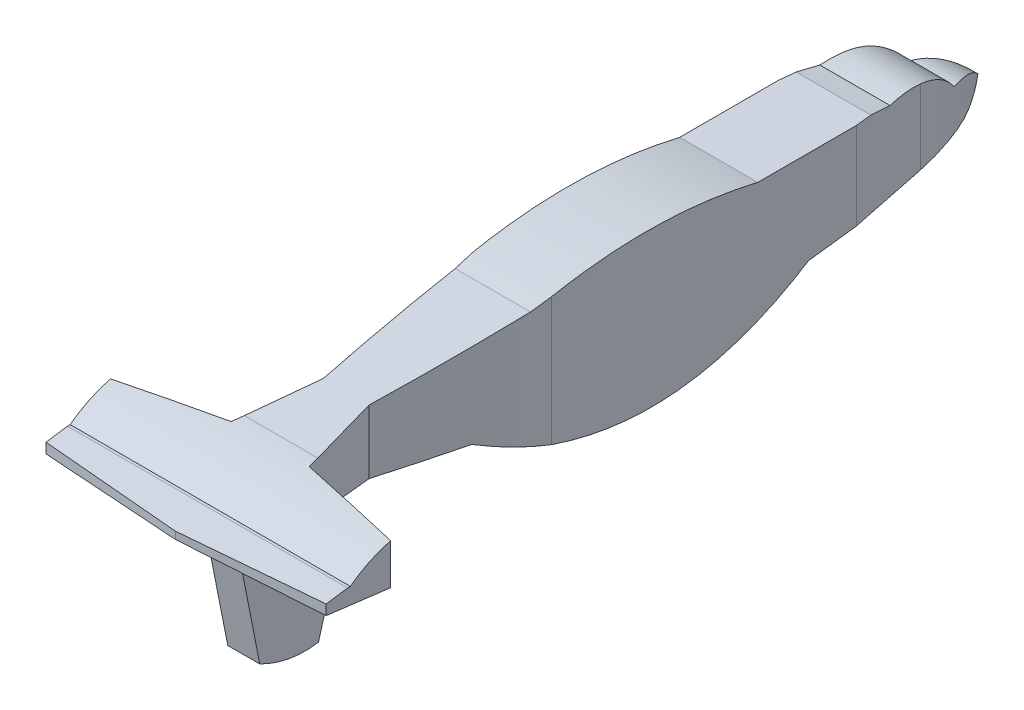
from build123d import *

# Parameters (mm, degrees)
BOSS_EXTRUDE1_DEPTH      = 240
SKETCH4_OUTSIDE_W        = 620.683
SKETCH4_OUTSIDE_H        = 358.674
CUT_EXTRUDE1_DEPTH       = 251.005507708
BOSS_EXTRUDE2_DEPTH      = 10
BOSS_EXTRUDE2_DEPTH_BACK = 10


with BuildPart() as part:
    # Sketch3 → Boss-Extrude1 (new body)
    with BuildSketch(Plane(origin=(0, 0, 0), x_dir=(1, 0, 0), z_dir=(0, 1, 0))):
        with BuildLine():
            Line((137.970364324, 414.272883639), (137.970364324, 223.69340993))
            add(Edge.make_bspline(
                [(137.970364324, 223.69340993), (141.476966078, 171.478024708), (148.044741181, 119.610332165)],
                knots=[0, 0, 0, 0.887153435, 0.887153435, 0.887153435], degree=2))
            Line((148.044741181, 119.610332165), (137.970364324, 72.071329968))
            Line((137.970364324, 72.071329968), (74.77736212, 59.754974694))
            Line((74.77736212, 59.754974694), (74.77736212, 19.446902889))
            Line((74.77736212, 19.446902889), (162.391434864, 12.728890921))
            Line((162.391434864, 12.728890921), (250.005507608, 19.446902889))
            Line((250.005507608, 19.446902889), (250.005507608, 59.754974694))
            Line((250.005507608, 59.754974694), (186.812505404, 72.071329968))
            Line((186.812505404, 72.071329968), (176.738128547, 119.610332165))
            add(Edge.make_bspline(
                [(186.812505404, 223.69340993), (183.30590365, 171.478024708), (176.738128547, 119.610332165)],
                knots=[0, 0, 0, 0.887153435, 0.887153435, 0.887153435], degree=2))
            Line((186.812505404, 223.69340993), (186.812505404, 414.272883639))
            Line((186.812505404, 414.272883639), (182.139885098, 458.943511131))
            add(Edge.make_bspline(
                [(182.139885098, 458.943511131), (178.393317936, 491.021832881), (162.391434864, 514.737632441)],
                knots=[0, 0, 0, 0.490132675, 0.490132675, 0.490132675], degree=2))
            add(Edge.make_bspline(
                [(142.64298463, 458.943511131), (146.389551792, 491.021832881), (162.391434864, 514.737632441)],
                knots=[0, 0, 0, 0.490132675, 0.490132675, 0.490132675], degree=2))
            Line((142.64298463, 458.943511131), (137.970364324, 414.272883639))
        make_face()
    extrude(amount=BOSS_EXTRUDE1_DEPTH)

    # Sketch4 outside → Cut-Extrude1 (cut, through all)
    with BuildSketch(Plane(origin=(0, 0, 0), x_dir=(0, 0, -1), z_dir=(1, 0, 0))):
        with Locations((263.7335, 120)):
            Rectangle(SKETCH4_OUTSIDE_W, SKETCH4_OUTSIDE_H)
        with BuildLine():
            Line((12.728890921, 85.924982425), (46.991957136, 81.651030623))
            Line((46.991957136, 81.651030623), (177.382016131, 65.386262487))
            add(Edge.make_bspline(
                [(177.382016131, 65.386262487), (287.640309593, 1.862307292), (384.386809277, 63.333754572)],
                knots=[0, 0, 0, 1, 1, 1], degree=2))
            Line((384.386809277, 63.333754572), (489.693965282, 76.663405275))
            add(Edge.make_bspline(
                [(489.693965282, 76.663405275), (505.317689733, 77.809278687), (514.737632441, 87.136419671)],
                knots=[0, 0, 0, 0.756426815, 0.756426815, 0.756426815], degree=2))
            add(Edge.make_bspline(
                [(514.737632441, 87.136419671), (501.382115592, 101.295387019), (485.88559641, 101.608221382)],
                knots=[0, 0, 0, 0.70811857, 0.70811857, 0.70811857], degree=2))
            add(Edge.make_bspline(
                [(485.88559641, 101.608221382), (473.943480605, 117.077174504), (457.892628594, 123.023372981), (437.733040377, 119.446816811)],
                knots=[0, 0, 0, 0, 0.856300563, 0.856300563, 0.856300563, 0.856300563], degree=3))
            Line((437.733040377, 119.446816811), (424.380439139, 121.602157956))
            Line((424.380439139, 121.602157956), (352.592685915, 121.602157956))
            add(Edge.make_bspline(
                [(352.592685915, 121.602157956), (283.160705497, 138.135189476), (211.297296684, 121.602157956)],
                knots=[0, 0, 0, 1, 1, 1], degree=2))
            Line((211.297296684, 121.602157956), (132.668959601, 113.79500177))
            Line((132.668959601, 113.79500177), (78.849169619, 108.45113311))
            add(Edge.make_bspline(
                [(78.849169619, 108.45113311), (52.309636156, 107.107843422), (34.577807776, 93.377447612)],
                knots=[0, 0, 0, 0.568417753, 0.568417753, 0.568417753], degree=2))
            Line((34.577807776, 93.377447612), (32.858632307, 93.377447612))
            Line((32.858632307, 93.377447612), (12.728890921, 90.430289665))
            Line((12.728890921, 90.430289665), (12.728890921, 85.924982425))
        make_face(mode=Mode.SUBTRACT)
    extrude(amount=CUT_EXTRUDE1_DEPTH, mode=Mode.SUBTRACT)

    # Sketch5 → Boss-Extrude2 (add, two sides)
    with BuildSketch(Plane.ZY.offset(-162.391434864)) as boss_extrude2_sk:
        with BuildLine():
            Line((-39.600938792, 82.572981273), (-55.527663258, 2.06573062))
            add(Edge.make_bspline(
                [(-55.527663258, 2.06573062), (-74.440482287, -7.393827092), (-92.263908139, -4.476340386)],
                knots=[0, 0, 0, 0.637969312, 0.637969312, 0.637969312], degree=2))
            Line((-92.263908139, -4.476340386), (-107.864231307, 50.87964505))
            Line((-107.864231307, 50.87964505), (-107.864231307, 74.057864143))
            Line((-107.864231307, 74.057864143), (-39.600938792, 82.572981273))
        make_face()
    extrude(amount=BOSS_EXTRUDE2_DEPTH)
    extrude(boss_extrude2_sk.sketch, amount=-BOSS_EXTRUDE2_DEPTH_BACK)


solid = part.part
